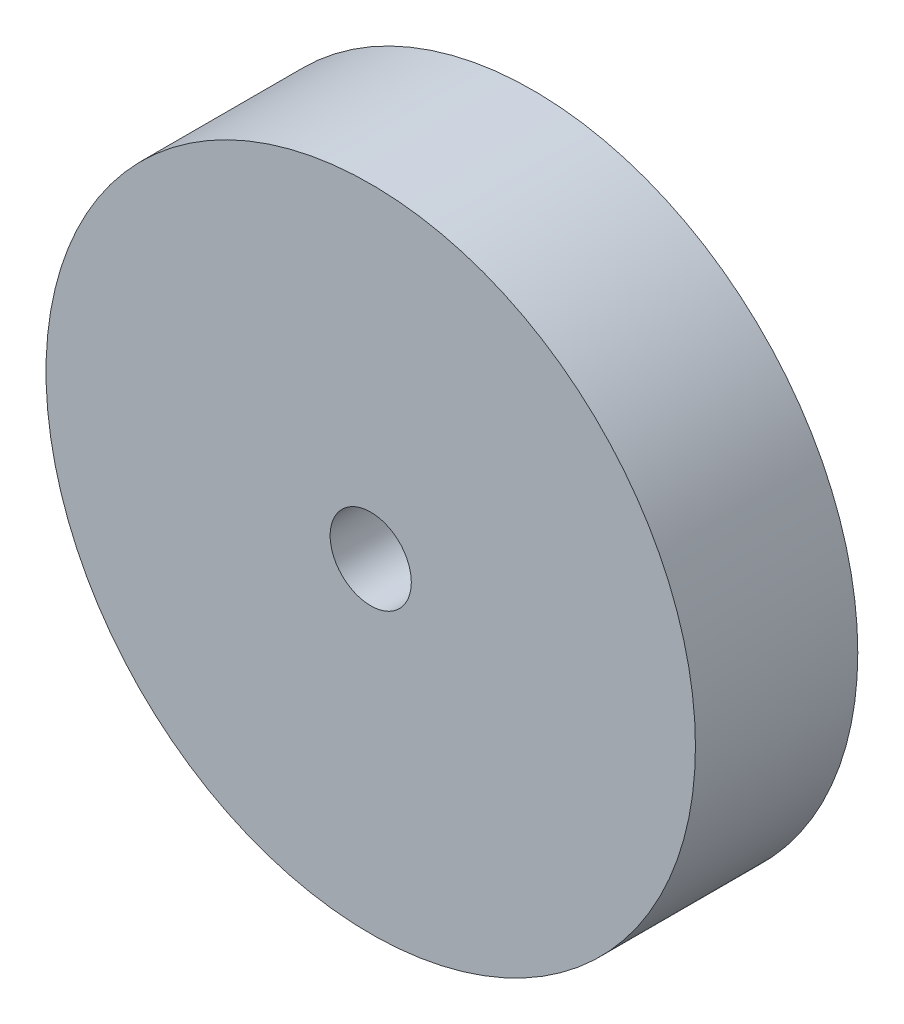
from build123d import *

# Parameters (mm, degrees)
ESQUISSE1_R        = 10
ESQUISSE1_R_2      = 1.25
BOSS_EXTRU_1_DEPTH = 5


with BuildPart() as part:
    # Esquisse1 → Boss.-Extru.1 (new body)
    with BuildSketch(Plane.XY):
        Circle(ESQUISSE1_R)
        Circle(ESQUISSE1_R_2, mode=Mode.SUBTRACT)
    extrude(amount=BOSS_EXTRU_1_DEPTH)


solid = part.part
